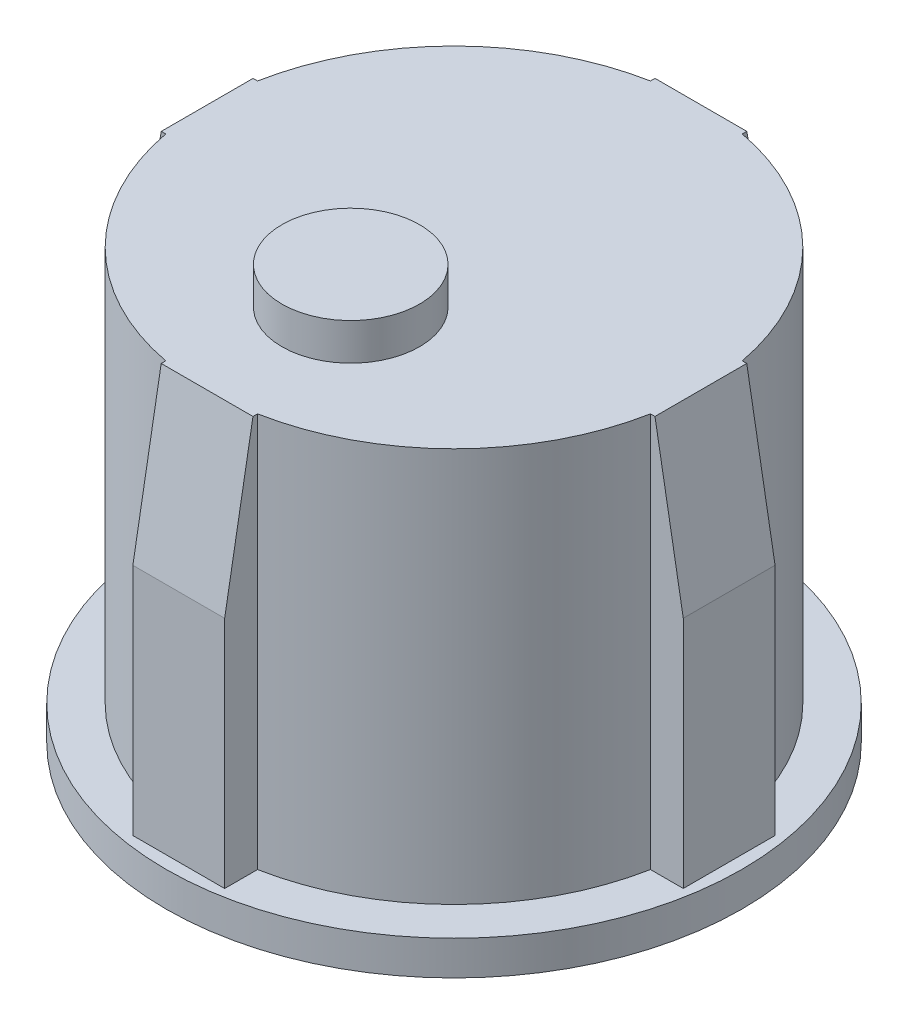
from build123d import *

# Parameters (mm, degrees)
SKETCH1_R             = 12.55
BOSS_EXTRUDE1_DEPTH   = 1.5
SKETCH2_R             = 10.75
BOSS_EXTRUDE2_DEPTH   = 17.2
BOSS_EXTRUDE3_DEPTH   = 17.2
SKETCH4_R             = 3
BOSS_EXTRUDE4_DEPTH   = 1.61
SKETCH5_R             = 7
SKETCH5_R_2           = 6
CUT_EXTRUDE1_DEPTH    = 1
CHAMFER1_SIZE         = 7
CHAMFER1_SIZE2        = 1.234288865
CHAMFER1_PART_2_SIZE  = 7
CHAMFER1_PART_2_SIZE2 = 1.234288865
CHAMFER1_PART_3_SIZE  = 7
CHAMFER1_PART_3_SIZE2 = 1.234288865
CHAMFER1_PART_4_SIZE  = 7
CHAMFER1_PART_4_SIZE2 = 1.234288865


with BuildPart() as part:
    # Sketch1 → Boss-Extrude1 (new body)
    with BuildSketch(Plane(origin=(0, 0, 0), x_dir=(1, 0, 0), z_dir=(0, 1, 0))):
        Circle(SKETCH1_R)
    extrude(amount=BOSS_EXTRUDE1_DEPTH)

    # Sketch2 → Boss-Extrude2 (add)
    with BuildSketch(Plane(origin=(0, 1.5, 0), x_dir=(1, 0, 0), z_dir=(0, 1, 0))):
        Circle(SKETCH2_R)
    extrude(amount=BOSS_EXTRUDE2_DEPTH)

    # Sketch3 → Boss-Extrude3 (add)
    with BuildSketch(Plane(origin=(0, 1.5, 0), x_dir=(1, 0, 0), z_dir=(0, 1, 0))):
        with BuildLine():
            Line((2, 11.994879818), (-2, 11.994879818))
            Line((-2, 11.994879818), (-2, 10.562315087))
            ThreePointArc((-2, 10.562315087), (0, 10.75), (2, 10.562315087))
            Line((2, 10.562315087), (2, 11.994879818))
        make_face()
        with BuildLine():
            Line((-11.992315087, -2), (-11.992315087, 2))
            Line((-11.992315087, 2), (-10.562315087, 2))
            ThreePointArc((-10.562315087, 2), (-10.75, 0), (-10.562315087, -2))
            Line((-10.562315087, -2), (-11.992315087, -2))
        make_face()
        with BuildLine():
            Line((-2, -11.994879818), (-2, -10.562315087))
            ThreePointArc((-2, -10.562315087), (0, -10.75), (2, -10.562315087))
            Line((2, -10.562315087), (2, -11.994879818))
            Line((2, -11.994879818), (-2, -11.994879818))
        make_face()
        with BuildLine():
            Line((11.992315087, -2), (10.562315087, -2))
            ThreePointArc((10.562315087, -2), (10.75, 0), (10.562315087, 2))
            Line((10.562315087, 2), (11.992315087, 2))
            Line((11.992315087, 2), (11.992315087, -2))
        make_face()
    extrude(amount=BOSS_EXTRUDE3_DEPTH)

    # Sketch4 → Boss-Extrude4 (add)
    with BuildSketch(Plane(origin=(0, 18.7, 0), x_dir=(1, 0, 0), z_dir=(0, 1, 0))):
        with Locations((0, -4.5)):
            Circle(SKETCH4_R)
    extrude(amount=BOSS_EXTRUDE4_DEPTH)

    # Sketch5 → Cut-Extrude1 (cut)
    with BuildSketch(Plane.XZ):
        Circle(SKETCH5_R)
        Circle(SKETCH5_R_2, mode=Mode.SUBTRACT)
    extrude(amount=-CUT_EXTRUDE1_DEPTH, mode=Mode.SUBTRACT)

    # Chamfer1
    chamfer1_edges = [part.edges().sort_by_distance(p)[0] for p in [
        (0, 18.7, -11.994879818),
    ]]
    chamfer1_side = [part.faces().sort_by_distance(p)[0] for p in [
        (0, 10.1, -11.994879818),
    ]]
    chamfer(chamfer1_edges, length=CHAMFER1_SIZE, length2=CHAMFER1_SIZE2, reference=chamfer1_side[0])

    # Chamfer1 part 2
    chamfer1_part_2_edges = [part.edges().sort_by_distance(p)[0] for p in [
        (11.992315087, 18.7, 0),
    ]]
    chamfer1_part_2_side = [part.faces().sort_by_distance(p)[0] for p in [
        (11.992315087, 10.1, 0),
    ]]
    chamfer(chamfer1_part_2_edges, length=CHAMFER1_PART_2_SIZE, length2=CHAMFER1_PART_2_SIZE2, reference=chamfer1_part_2_side[0])

    # Chamfer1 part 3
    chamfer1_part_3_edges = [part.edges().sort_by_distance(p)[0] for p in [
        (-11.992315087, 18.7, 0),
    ]]
    chamfer1_part_3_side = [part.faces().sort_by_distance(p)[0] for p in [
        (-11.992315087, 10.1, 0),
    ]]
    chamfer(chamfer1_part_3_edges, length=CHAMFER1_PART_3_SIZE, length2=CHAMFER1_PART_3_SIZE2, reference=chamfer1_part_3_side[0])

    # Chamfer1 part 4
    chamfer1_part_4_edges = [part.edges().sort_by_distance(p)[0] for p in [
        (0, 18.7, 11.994879818),
    ]]
    chamfer1_part_4_side = [part.faces().sort_by_distance(p)[0] for p in [
        (0, 10.1, 11.994879818),
    ]]
    chamfer(chamfer1_part_4_edges, length=CHAMFER1_PART_4_SIZE, length2=CHAMFER1_PART_4_SIZE2, reference=chamfer1_part_4_side[0])


solid = part.part
